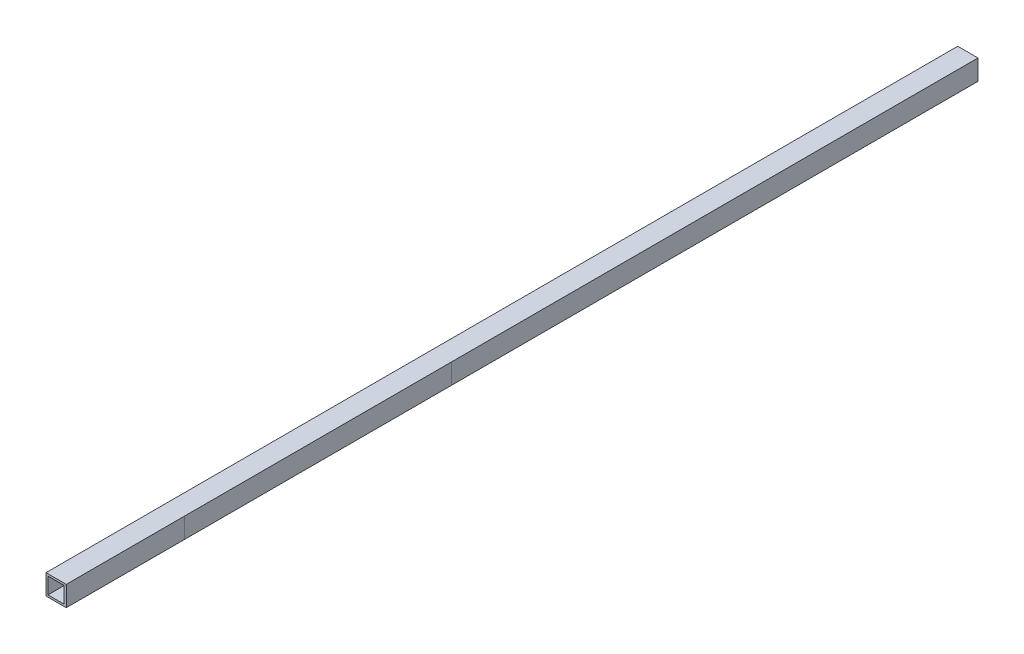
from build123d import *

# Parameters (mm, degrees)
IZIM1_W                     = 40
IZIM1_H                     = 40
IZIM1_W_2                   = 32
IZIM1_H_2                   = 32
Y_KSEKLIK_EKSTR_ZYON1_DEPTH = 1800


with BuildPart() as part:
    # Çizim1 → Yükseklik-Ekstrüzyon1 (new body)
    with BuildSketch(Plane.XY):
        with Locations((20, 20)):
            Rectangle(IZIM1_W, IZIM1_H)
        with Locations((20, 20)):
            Rectangle(IZIM1_W_2, IZIM1_H_2, mode=Mode.SUBTRACT)
    extrude(amount=-Y_KSEKLIK_EKSTR_ZYON1_DEPTH)


solid = part.part
